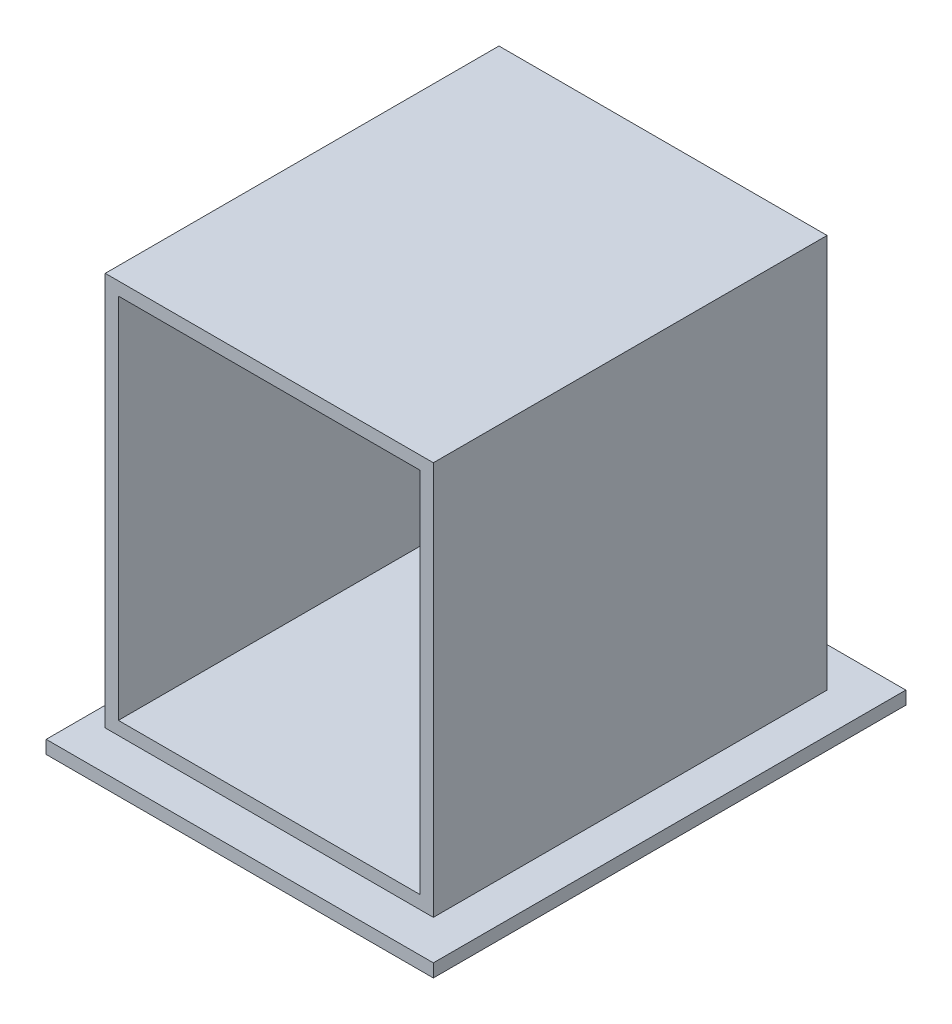
from build123d import *

# Parameters (mm, degrees)
SKETCH_1_W          = 250
SKETCH_1_H          = 300
EXTRUDE_1_DEPTH     = 300
SKETCH_2_W          = 230
SKETCH_2_H          = 280
CUT_EXTRUDE_1_DEPTH = 290
SKETCH_3_W          = 295
SKETCH_3_H          = 360
EXTRUDE_2_DEPTH     = 10
CUT_EXTRUDE_2_DEPTH = 10


with BuildPart() as part:
    # 草图1 → 凸台-拉伸1 (new body)
    with BuildSketch(Plane.XY):
        with Locations((125, 150)):
            Rectangle(SKETCH_1_W, SKETCH_1_H)
    extrude(amount=EXTRUDE_1_DEPTH)

    # 草图2 → 切除-拉伸1 (cut)
    with BuildSketch(Plane.XY.offset(300)):
        with Locations((125, 150)):
            Rectangle(SKETCH_2_W, SKETCH_2_H)
    extrude(amount=-CUT_EXTRUDE_1_DEPTH, mode=Mode.SUBTRACT)

    # 草图3 → 凸台-拉伸2 (add)
    with BuildSketch(Plane.XZ):
        with Locations((132.5, 150)):
            Rectangle(SKETCH_3_W, SKETCH_3_H)
    extrude(amount=EXTRUDE_2_DEPTH)

    # 草图4 → 切除-拉伸2 (cut)
    with BuildSketch(Plane(origin=(0, -10, 0), x_dir=(-1, 0, 0), z_dir=(0, -1, 0))):
        with BuildLine():
            Line((-101.811483313, -287.738071641), (-183.649909723, -287.738071641))
            ThreePointArc((-183.649909723, -287.738071641), (-201.387981364, -270), (-183.649909723, -252.261928359))
            Line((-183.649909723, -252.261928359), (-101.811483313, -252.261928359))
            ThreePointArc((-101.811483313, -252.261928359), (-84.073411671, -270), (-101.811483313, -287.738071641))
        make_face()
    extrude(amount=-CUT_EXTRUDE_2_DEPTH, mode=Mode.SUBTRACT)


solid = part.part
